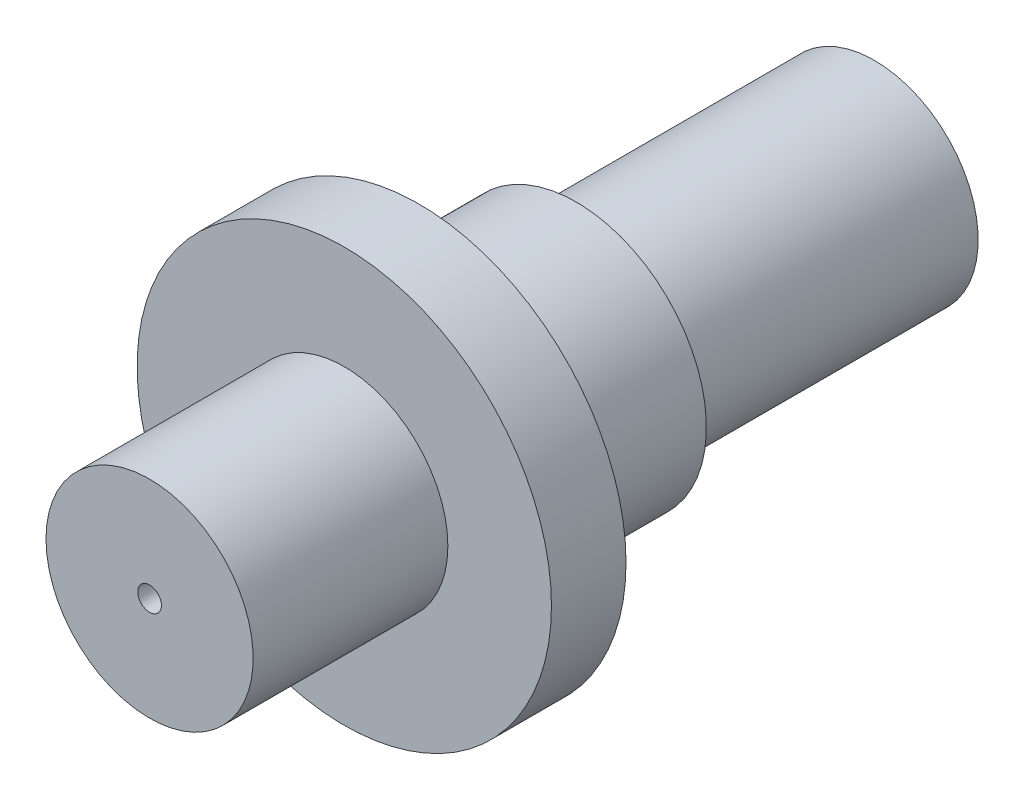
from build123d import *

# Parameters (mm, degrees)
SKETCH1_R           = 6.35
BOSS_EXTRUDE1_DEPTH = 2.286
SKETCH2_R           = 3.175
BOSS_EXTRUDE2_DEPTH = 8.255
SKETCH3_R           = 3.9878
BOSS_EXTRUDE3_DEPTH = 4.826
SKETCH4_R           = 3.175
BOSS_EXTRUDE4_DEPTH = 9.144
SKETCH5_R           = 0.362927277
CUT_EXTRUDE1_DEPTH  = 23.225


with BuildPart() as part:
    # Sketch1 → Boss-Extrude1 (new body)
    with BuildSketch(Plane.XY):
        Circle(SKETCH1_R)
    extrude(amount=BOSS_EXTRUDE1_DEPTH)

    # Sketch2 → Boss-Extrude2 (add)
    with BuildSketch(Plane(origin=(0, 0, 0), x_dir=(-1, 0, 0), z_dir=(0, 0, -1))):
        Circle(SKETCH2_R)
    extrude(amount=-BOSS_EXTRUDE2_DEPTH)

    # Sketch3 → Boss-Extrude3 (add)
    with BuildSketch(Plane(origin=(0, 0, 0), x_dir=(-1, 0, 0), z_dir=(0, 0, -1))):
        Circle(SKETCH3_R)
    extrude(amount=BOSS_EXTRUDE3_DEPTH)

    # Sketch4 → Boss-Extrude4 (add)
    with BuildSketch(Plane(origin=(0, 0, -4.826), x_dir=(-1, 0, 0), z_dir=(0, 0, -1))):
        Circle(SKETCH4_R)
    extrude(amount=BOSS_EXTRUDE4_DEPTH)

    # Sketch5 → Cut-Extrude1 (cut, through all)
    with BuildSketch(Plane.XY.offset(8.255)):
        Circle(SKETCH5_R)
    extrude(amount=-CUT_EXTRUDE1_DEPTH, mode=Mode.SUBTRACT)


solid = part.part
